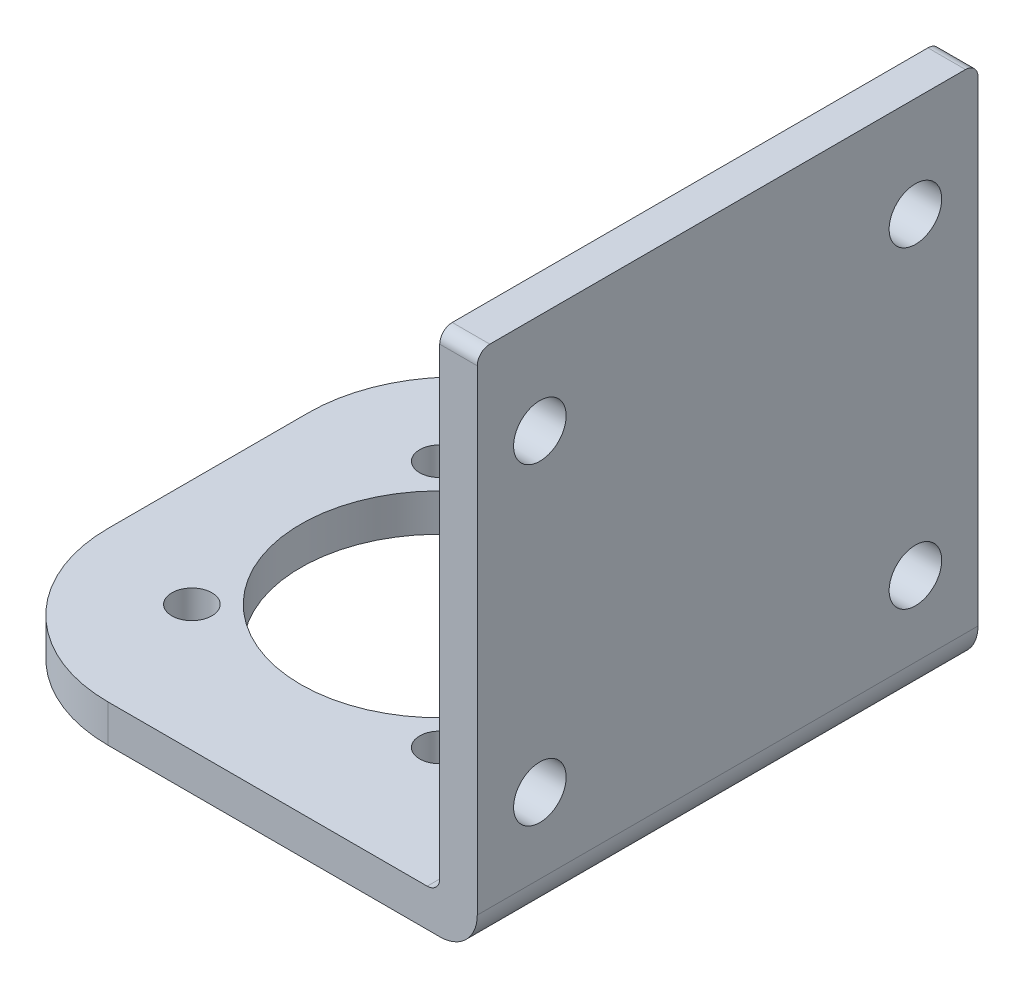
from build123d import *

# Parameters (mm, degrees)
EXTRUDE_1_DEPTH     = 40
SKETCH_2_R          = 2.1
CUT_EXTRUDE_1_DEPTH = 3
SKETCH_3_R          = 11.1
SKETCH_3_R_2        = 1.6
CUT_EXTRUDE_2_DEPTH = 3
FILLET_1_R          = 3
FILLET_2_R          = 12
FILLET_3_R          = 1
FILLET_4_R          = 1


with BuildPart() as part:
    # 草图1 → 凸台-拉伸1 (new body)
    with BuildSketch(Plane.XY):
        Polygon((0, 3), (0, 0), (38.5, 0), (41.5, 0), (41.5, 3), (41.5, 42), (38.5, 42), (38.5, 3), align=None)
    extrude(amount=EXTRUDE_1_DEPTH)

    # 草图2 → 切除-拉伸1 (cut)
    with BuildSketch(Plane(origin=(41.5, 0, 0), x_dir=(0, 0, -1), z_dir=(1, 0, 0))):
        with Locations((-35, 34)):
            Circle(SKETCH_2_R)
        with Locations((-5, 34)):
            Circle(SKETCH_2_R)
        with Locations((-35, 9)):
            Circle(SKETCH_2_R)
        with Locations((-5, 9)):
            Circle(SKETCH_2_R)
    extrude(amount=-CUT_EXTRUDE_1_DEPTH, mode=Mode.SUBTRACT)

    # 草图3 → 切除-拉伸2 (cut)
    with BuildSketch(Plane.XZ):
        with Locations((18.5, 20)):
            Circle(SKETCH_3_R)
        with Locations((8.600505063, 29.899494937)):
            Circle(SKETCH_3_R_2)
        with Locations((28.399494937, 29.899494937)):
            Circle(SKETCH_3_R_2)
        with Locations((28.399494937, 10.100505063)):
            Circle(SKETCH_3_R_2)
        with Locations((8.600505063, 10.100505063)):
            Circle(SKETCH_3_R_2)
    extrude(amount=-CUT_EXTRUDE_2_DEPTH, mode=Mode.SUBTRACT)

    # 圆角1
    fillet_1_edges = [part.edges().sort_by_distance(p)[0] for p in [
        (41.5, 0, 20),
    ]]
    fillet(fillet_1_edges, radius=FILLET_1_R)

    # 圆角2
    fillet_2_edges = [part.edges().sort_by_distance(p)[0] for p in [
        (0, 1.5, 40),
        (0, 1.5, 0),
    ]]
    fillet(fillet_2_edges, radius=FILLET_2_R)

    # 圆角3
    fillet_3_edges = [part.edges().sort_by_distance(p)[0] for p in [
        (40, 42, 40),
        (40, 42, 0),
    ]]
    fillet(fillet_3_edges, radius=FILLET_3_R)

    # 圆角4
    fillet_4_edges = [part.edges().sort_by_distance(p)[0] for p in [
        (38.5, 3, 20),
    ]]
    fillet(fillet_4_edges, radius=FILLET_4_R)


solid = part.part
